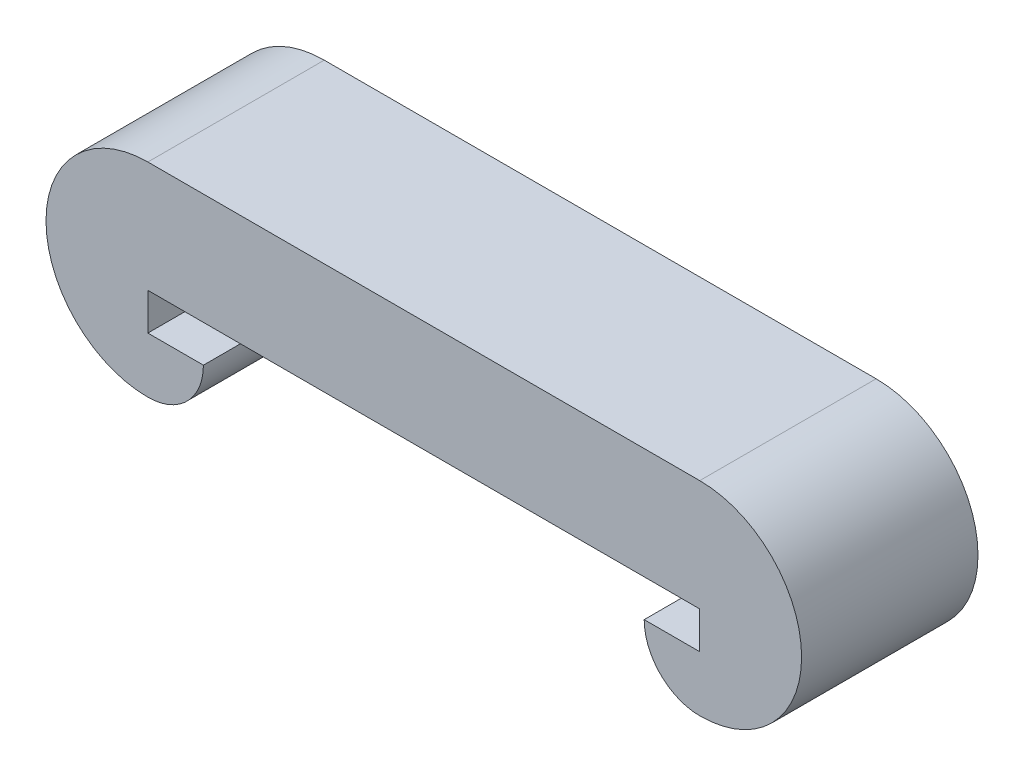
from build123d import *

# Parameters (mm, degrees)
BOSS_EXTRUDE1_DEPTH = 4.7625


with BuildPart() as part:
    # Sketch1 → Boss-Extrude1 (new body)
    with BuildSketch(Plane.XY):
        with BuildLine():
            Line((-7.45, 3), (0, 3))
            Line((0, 3), (0, 0))
            Line((0, 0), (-7.45, 0))
            Line((-7.45, 0), (-7.45, -1))
            Line((-7.45, -1), (-5.95, -1))
            ThreePointArc((-5.95, -1), (-6.389339828, -2.060660172), (-7.45, -2.5))
            ThreePointArc((-7.45, -2.5), (-10.2, 0.25), (-7.45, 3))
        make_face()
    boss_extrude1 = extrude(amount=BOSS_EXTRUDE1_DEPTH)

    # Mirror1: Boss-Extrude1 across plane
    add(boss_extrude1.mirror(Plane(origin=(0, 0, 4.7625), x_dir=(0, 0, 1), z_dir=(-1, 0, 0))))


solid = part.part
